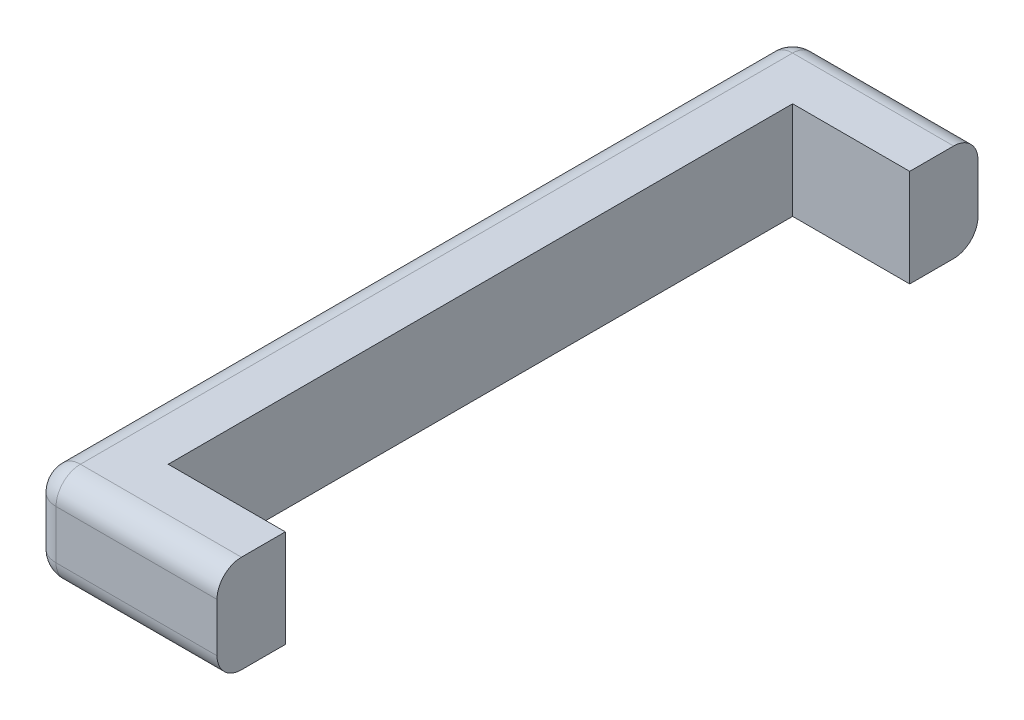
from build123d import *

# Parameters (mm, degrees)
BOSS_EXTRUDE1_DEPTH = 63.5
FILLET1_R           = 31.75
FILLET2_R           = 31.75


with BuildPart() as part:
    # Sketch2 → Boss-Extrude1 (new body, symmetric)
    with BuildSketch(Plane(origin=(0, 0, 0), x_dir=(1, 0, 0), z_dir=(0, 1, 0))):
        Polygon((241.3, -406.4), (241.3, -495.3), (0, -495.3), (0, 495.3), (241.3, 495.3), (241.3, 406.4), (88.9, 406.4), (88.9, -406.4), align=None)
    extrude(amount=BOSS_EXTRUDE1_DEPTH, both=True)

    # Fillet1
    fillet1_edges = [part.edges().sort_by_distance(p)[0] for p in [
        (0, 0, -495.3),
        (0, 0, 495.3),
    ]]
    fillet(fillet1_edges, radius=FILLET1_R)

    # Fillet2
    fillet2_edges = [part.edges().sort_by_distance(p)[0] for p in [
        (0, -63.5, 0),
        (0, 63.5, 0),
        (136.525, 63.5, -495.3),
        (136.525, -63.5, 495.3),
        (9.299359697, -63.5, 486.000640303),
        (9.299359697, -63.5, -486.000640303),
        (136.525, 63.5, 495.3),
        (9.299359697, 63.5, 486.000640303),
        (9.299359697, 63.5, -486.000640303),
        (136.525, -63.5, -495.3),
    ]]
    fillet(fillet2_edges, radius=FILLET2_R)


solid = part.part
